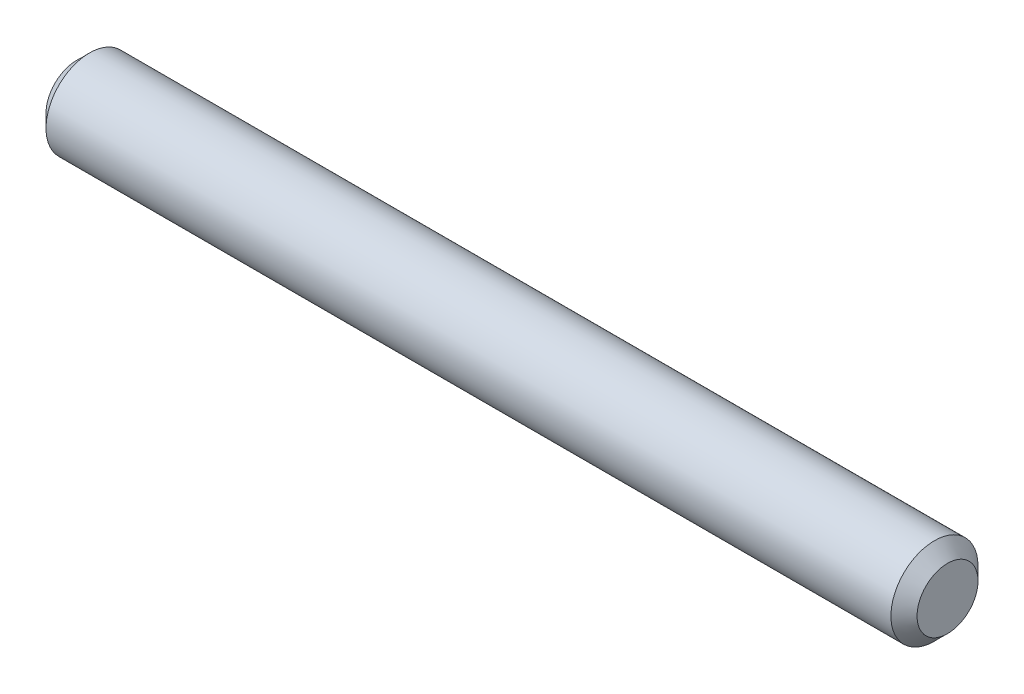
from build123d import *

# Parameters (mm, degrees)
SKETCH2_R                = 3.175
BOSS_EXTRUDE1_DEPTH      = 31.75
BOSS_EXTRUDE1_DEPTH_BACK = 31.75
CHAMFER1_SIZE            = 0.9525


with BuildPart() as part:
    # Sketch2 → Boss-Extrude1 (new body, two sides)
    with BuildSketch(Plane(origin=(0, 0, 0), x_dir=(0, 0, -1), z_dir=(1, 0, 0))) as boss_extrude1_sk:
        Circle(SKETCH2_R)
    extrude(amount=BOSS_EXTRUDE1_DEPTH)
    extrude(boss_extrude1_sk.sketch, amount=-BOSS_EXTRUDE1_DEPTH_BACK)

    # Chamfer1
    chamfer1_edges = [part.edges().sort_by_distance(p)[0] for p in [
        (-31.75, 0, 3.175),
        (31.75, 0, 3.175),
    ]]
    chamfer(chamfer1_edges, length=CHAMFER1_SIZE)


solid = part.part
